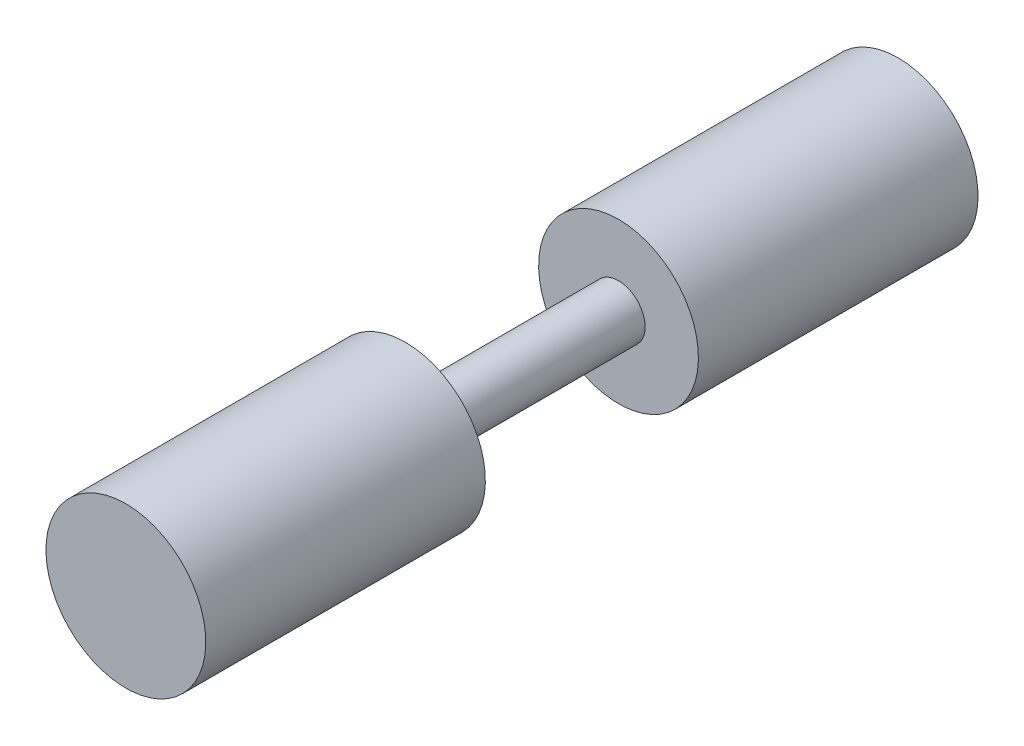
from build123d import *


with BuildPart() as part:
    # Sketch1 → Revolve1 (revolve)
    with BuildSketch(Plane(origin=(0, 0, 0), x_dir=(0, 0, -1), z_dir=(1, 0, 0))):
        Polygon((92.075, 0), (-92.075, 0), (-92.075, 19.05), (-25.4, 19.05), (-25.4, 6.35), (25.4, 6.35), (25.4, 19.05), (92.075, 19.05), align=None)
    revolve(axis=Axis((0, 0, -92.075), (0, 0, 1)))


solid = part.part
